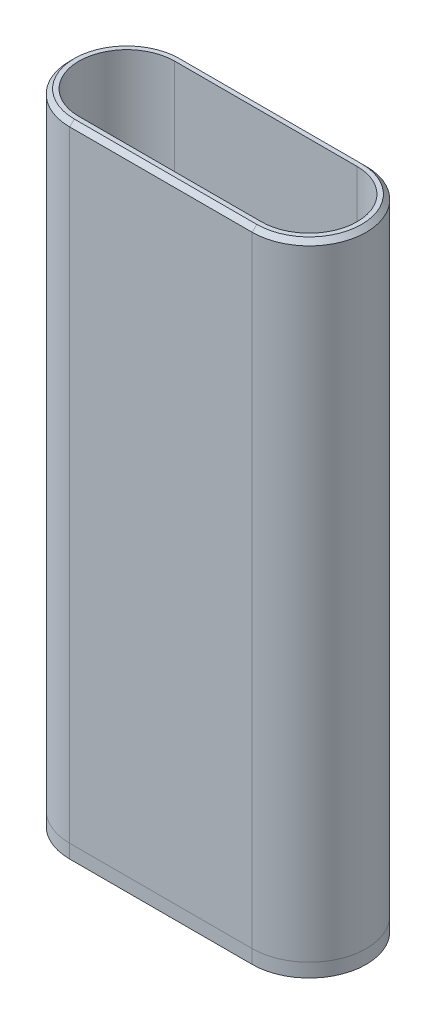
from build123d import *

# Parameters (mm, degrees)
SKETCH2_W                     = 14.9
SKETCH2_H                     = 11.3
SKETCH2_W_2                   = 8.3
SKETCH2_H_2                   = 7.3
BOSS_EXTRUDE1_DEPTH           = 12.6
SKETCH4_W                     = 4.6
SKETCH4_H                     = 3.1
CUT_EXTRUDE1_DEPTH            = 8.45
CUT_EXTRUDE1_DEPTH_BACK       = 8.45
BOSS_EXTRUDE2_DEPTH           = 3
BOSS_EXTRUDE3_DEPTH           = 137
SKETCH8_W                     = 28.9
SKETCH8_H                     = 15.3
BOSS_EXTRUDE4_DEPTH           = 7.2
SKETCH11_W                    = 1.8
SKETCH11_H                    = 137
M3_CLEARANCE_HOLE1_AT_2_COUNT = 2
M3_CLEARANCE_HOLE1_AT_2_PITCH = 40
CUT_EXTRUDE2_DEPTH            = 3
CUT_EXTRUDE3_DEPTH            = 0.3
SKETCH15_W                    = 3.6
SKETCH15_H                    = 3.6
CUT_EXTRUDE4_DEPTH            = 0.3
CHAMFER1_SIZE                 = 1
CHAMFER2_SIZE                 = 1.5


with BuildPart() as part:
    # Sketch2 → Boss-Extrude1 (new body)
    with BuildSketch(Plane.XZ.offset(-12)):
        Rectangle(SKETCH2_W, SKETCH2_H)
        Rectangle(SKETCH2_W_2, SKETCH2_H_2, mode=Mode.SUBTRACT)
    extrude(amount=BOSS_EXTRUDE1_DEPTH)

    # Sketch4 → Cut-Extrude1 (cut, two sides)
    with BuildSketch(Plane(origin=(0, 0, 0), x_dir=(0, 0, -1), z_dir=(1, 0, 0))) as cut_extrude1_sk:
        with Locations((0, 8.55)):
            Rectangle(SKETCH4_W, SKETCH4_H)
    extrude(amount=CUT_EXTRUDE1_DEPTH, mode=Mode.SUBTRACT)
    extrude(cut_extrude1_sk.sketch, amount=-CUT_EXTRUDE1_DEPTH_BACK, mode=Mode.SUBTRACT)

    # Sketch5 → Boss-Extrude2 (add)
    with BuildSketch(Plane.XZ.offset(0.6)):
        with BuildLine():
            Line((-20, 12.5), (20, 12.5))
            ThreePointArc((20, 12.5), (32.5, 0), (20, -12.5))
            Line((20, -12.5), (-20, -12.5))
            ThreePointArc((-20, -12.5), (-32.5, 0), (-20, 12.5))
        make_face()
    extrude(amount=BOSS_EXTRUDE2_DEPTH)


with BuildPart() as body_2:
    # Sketch7 → Boss-Extrude3 (new body)
    with BuildSketch(Plane(origin=(0, -0.6, 0), x_dir=(1, 0, 0), z_dir=(0, 1, 0))):
        with BuildLine():
            Line((-20, -12.5), (20, -12.5))
            ThreePointArc((20, -12.5), (32.5, 0), (20, 12.5))
            Line((20, 12.5), (-20, 12.5))
            ThreePointArc((-20, 12.5), (-32.5, 0), (-20, -12.5))
        make_face()
        with BuildLine():
            Line((-20, -10.5), (20, -10.5))
            ThreePointArc((20, -10.5), (30.5, 0), (20, 10.5))
            Line((20, 10.5), (-20, 10.5))
            ThreePointArc((-20, 10.5), (-30.5, 0), (-20, -10.5))
        make_face(mode=Mode.SUBTRACT)
    extrude(amount=BOSS_EXTRUDE3_DEPTH)

    # Sketch8 → Boss-Extrude4 (add)
    with BuildSketch(Plane.XZ.offset(0.6)):
        with BuildLine():
            Line((20, -12.5), (-20, -12.5))
            ThreePointArc((-20, -12.5), (-32.5, 0), (-20, 12.5))
            Line((-20, 12.5), (20, 12.5))
            ThreePointArc((20, 12.5), (32.5, 0), (20, -12.5))
        make_face()
        Rectangle(SKETCH8_W, SKETCH8_H, mode=Mode.SUBTRACT)
    extrude(amount=-BOSS_EXTRUDE4_DEPTH)

    # Sketch11 → M3 Clearance Hole1 (revolve, cut)
    with BuildSketch(Plane(origin=(-20, -0.6, 0), x_dir=(0, 0, -1), z_dir=(1, 0, 0))):
        with Locations((0.9, 68.5)):
            Rectangle(SKETCH11_W, SKETCH11_H)
    m3_clearance_hole1 = revolve(axis=Axis((-20, -6.95, 0), (0, 1, 0)), mode=Mode.SUBTRACT)

    # M3 Clearance Hole1 at 2: M3 Clearance Hole1 ×2
    with Locations(*[(i * M3_CLEARANCE_HOLE1_AT_2_PITCH, 0, 0) for i in range(1, M3_CLEARANCE_HOLE1_AT_2_COUNT)]):
        add(m3_clearance_hole1, mode=Mode.SUBTRACT)

    # Sketch13 → Cut-Extrude2 (cut)
    with BuildSketch(Plane(origin=(0, 1.4, 0), x_dir=(1, 0, 0), z_dir=(0, 1, 0))):
        Polygon((-14.45, -2.85), (-18.354551733, -2.85), (-16.709103466, 0), (-18.354551733, 2.85), (-14.45, 2.85), align=None)
        Polygon((-18.354551733, -2.85), (-16.709103466, 0), (-18.354551733, 2.85), (-21.645448267, 2.85), (-23.290896534, 0), (-21.645448267, -2.85), align=None)
    cut_extrude2 = extrude(amount=CUT_EXTRUDE2_DEPTH, mode=Mode.SUBTRACT)

    # Sketch14 → Cut-Extrude3 (cut)
    with BuildSketch(Plane.XZ.offset(-4.4)):
        with BuildLine():
            ThreePointArc((-18.2, 0), (-20.00000001, -1.8), (-21.8, 2e-08))
            Line((-21.8, 2e-08), (-21.8, -2.582308546))
            Line((-21.8, -2.582308546), (-21.645448267, -2.85))
            Line((-21.645448267, -2.85), (-18.2, -2.85))
            Line((-18.2, -2.85), (-18.2, 0))
        make_face()
        with BuildLine():
            Line((-18.2, 2.85), (-21.645448267, 2.85))
            Line((-21.645448267, 2.85), (-21.8, 2.582308546))
            Line((-21.8, 2.582308546), (-21.8, 2e-08))
            ThreePointArc((-21.8, 2e-08), (-19.99999999, 1.8), (-18.2, 0))
            Line((-18.2, 0), (-18.2, 2.85))
        make_face()
    cut_extrude3 = extrude(amount=-CUT_EXTRUDE3_DEPTH, mode=Mode.SUBTRACT)

    # Sketch15 → Cut-Extrude4 (cut)
    with BuildSketch(Plane.XZ.offset(-4.7)):
        with Locations((-20, 0)):
            Rectangle(SKETCH15_W, SKETCH15_H)
    cut_extrude4 = extrude(amount=-CUT_EXTRUDE4_DEPTH, mode=Mode.SUBTRACT)

    # Chamfer1
    chamfer1_edges = [body_2.edges().sort_by_distance(p)[0] for p in [
        (32.5, 136.4, 0),
        (0, 136.4, -12.5),
        (-32.5, 136.4, 0),
        (0, 136.4, 12.5),
    ]]
    chamfer(chamfer1_edges, length=CHAMFER1_SIZE)

    # Mirror1: Cut-Extrude2, Cut-Extrude3, Cut-Extrude4 across plane
    add(cut_extrude2.mirror(Plane(origin=(0, 0, 0), x_dir=(0, 0, 1), z_dir=(1, 0, 0))), mode=Mode.SUBTRACT)
    add(cut_extrude3.mirror(Plane(origin=(0, 0, 0), x_dir=(0, 0, 1), z_dir=(1, 0, 0))), mode=Mode.SUBTRACT)
    add(cut_extrude4.mirror(Plane(origin=(0, 0, 0), x_dir=(0, 0, 1), z_dir=(1, 0, 0))), mode=Mode.SUBTRACT)

    # Chamfer2
    chamfer2_edges = [body_2.edges().sort_by_distance(p)[0] for p in [
        (-14.45, -0.6, 0),
        (0, -0.6, 7.65),
        (14.45, -0.6, 0),
        (0, -0.6, -7.65),
    ]]
    chamfer(chamfer2_edges, length=CHAMFER2_SIZE)


solid = Compound([part.part, body_2.part])
